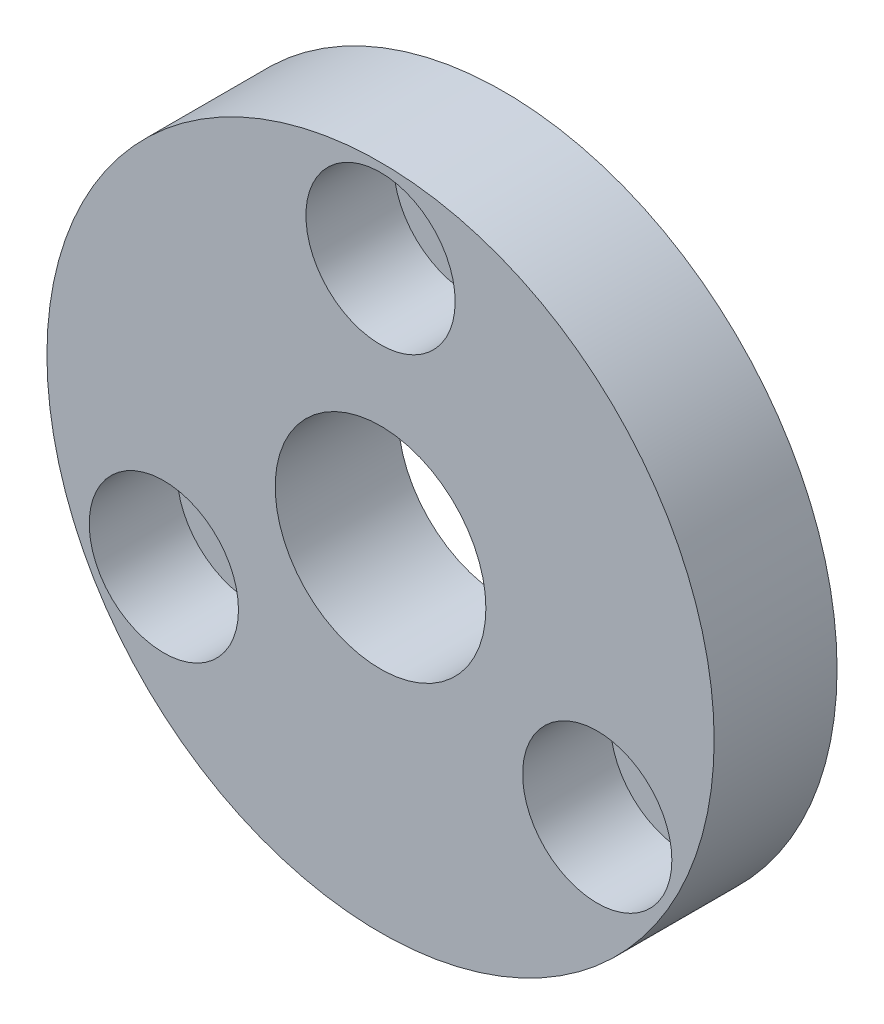
from build123d import *

# Parameters (mm, degrees)
ESQUISSE1_R      = 19
ESQUISSE1_R_2    = 6
ESQUISSE1_R_3    = 2.5
EXTRUSION1_DEPTH = 7
ESQUISSE2_R      = 4.25
EXTRUSION2_DEPTH = 5


with BuildPart() as part:
    # Esquisse1 → Extrusion1 (new body)
    with BuildSketch(Plane.XY):
        Circle(ESQUISSE1_R)
        Circle(ESQUISSE1_R_2, mode=Mode.SUBTRACT)
        with Locations((12.340862004, -7.125)):
            Circle(ESQUISSE1_R_3, mode=Mode.SUBTRACT)
        with Locations((0, 14.25)):
            Circle(ESQUISSE1_R_3, mode=Mode.SUBTRACT)
        with Locations((-12.340862004, -7.125)):
            Circle(ESQUISSE1_R_3, mode=Mode.SUBTRACT)
    extrude(amount=EXTRUSION1_DEPTH)

    # Esquisse2 → Extrusion2 (cut)
    with BuildSketch(Plane.XY.offset(7)):
        with Locations((0, 14.25)):
            Circle(ESQUISSE2_R)
        with Locations((-12.340862004, -7.125)):
            Circle(ESQUISSE2_R)
        with Locations((12.340862004, -7.125)):
            Circle(ESQUISSE2_R)
    extrude(amount=-EXTRUSION2_DEPTH, mode=Mode.SUBTRACT)


solid = part.part
